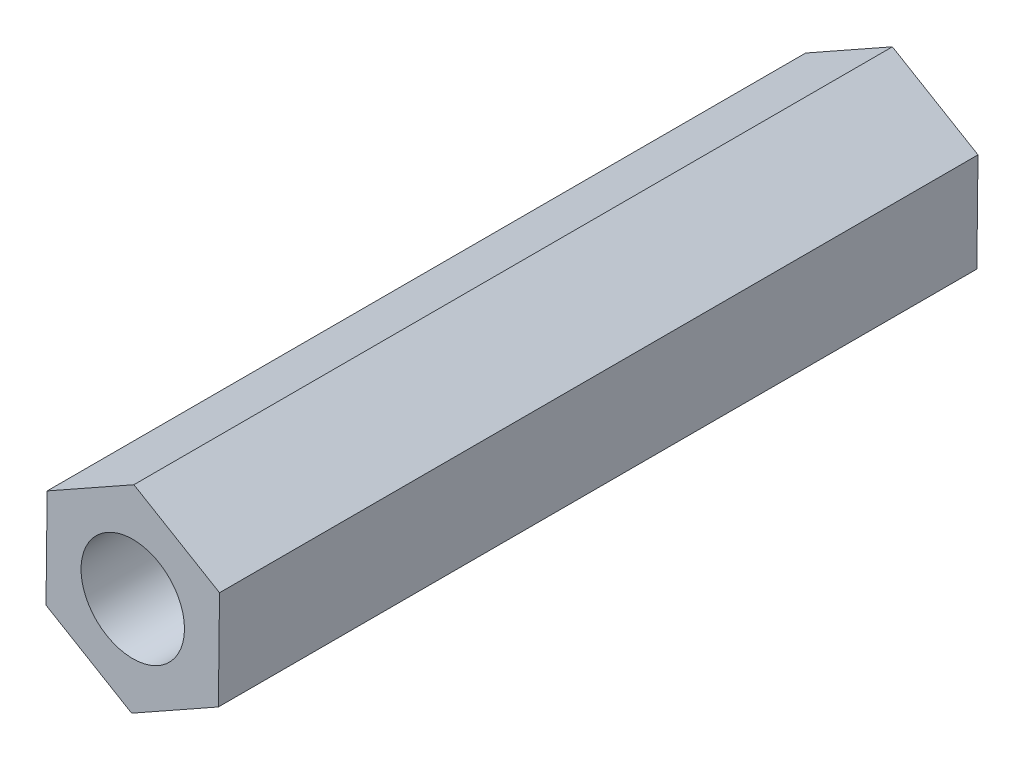
from build123d import *

# Parameters (mm, degrees)
IZIM1_R                     = 1.5
Y_KSEKLIK_EKSTR_ZYON1_DEPTH = 22


with BuildPart() as part:
    # Çizim1 → Yükseklik-Ekstrüzyon1 (new body)
    with BuildSketch(Plane.XY):
        Polygon((-2.483166464, 1.472147291), (-2.516500184, -1.414411594), (-0.03333372, -2.886558885), (2.483166464, -1.472147291), (2.516500184, 1.414411594), (0.03333372, 2.886558885), align=None)
        Circle(IZIM1_R, mode=Mode.SUBTRACT)
    extrude(amount=Y_KSEKLIK_EKSTR_ZYON1_DEPTH)


solid = part.part
